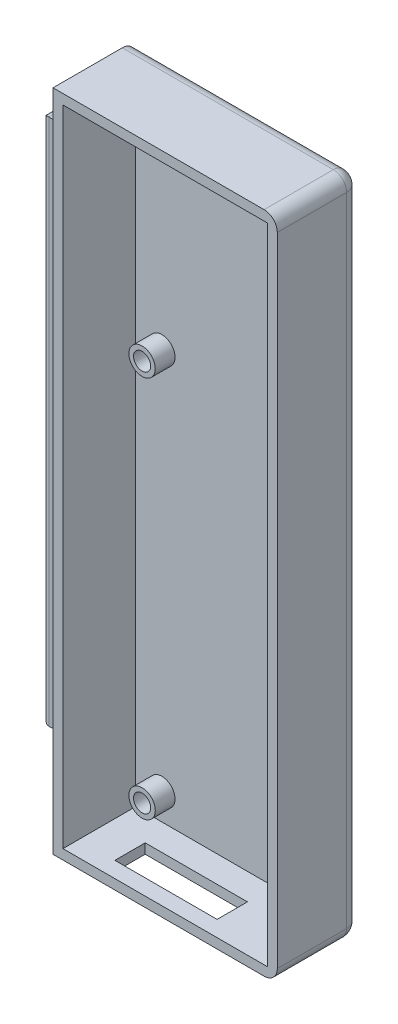
from build123d import *

# Parameters (mm, degrees)
ESQUISSE1_W             = 34
ESQUISSE1_H             = 100.65
BOSS_EXTRU_1_DEPTH      = 12.5
ESQUISSE2_W             = 31
ESQUISSE2_H             = 97.65
ENL_V_MAT_EXTRU_1_DEPTH = 11
ESQUISSE5_R             = 2
BOSS_EXTRU_4_DEPTH      = 3
CONG_2_R                = 2
CONG_3_R                = 2
CONG_4_R                = 2
ESQUISSE7_W             = 7.5
ESQUISSE7_H             = 80
BOSS_EXTRU_6_DEPTH      = 1
ESQUISSE9_W             = 9.45
ESQUISSE9_H             = 80
BOSS_EXTRU_7_DEPTH      = 1.7
ESQUISSE11_W            = 15.5
ESQUISSE11_H            = 4.6
ENL_V_MAT_EXTRU_3_DEPTH = 3
CONG_7_R                = 1
ESQUISSE12_R            = 1.3
ENL_V_MAT_EXTRU_5_DEPTH = 3


with BuildPart() as part:
    # Esquisse1 → Boss.-Extru.1 (new body)
    with BuildSketch(Plane.XY):
        with Locations((17, 50.325)):
            Rectangle(ESQUISSE1_W, ESQUISSE1_H)
    extrude(amount=BOSS_EXTRU_1_DEPTH)

    # Esquisse2 → Enlèv. mat.-Extru.1 (cut)
    with BuildSketch(Plane.XY.offset(12.5)):
        with Locations((17, 50.325)):
            Rectangle(ESQUISSE2_W, ESQUISSE2_H)
    extrude(amount=-ENL_V_MAT_EXTRU_1_DEPTH, mode=Mode.SUBTRACT)

    # Esquisse5 → Boss.-Extru.4 (add)
    with BuildSketch(Plane.XY.offset(1.5)):
        with Locations((5.5, 63.5)):
            Circle(ESQUISSE5_R)
        with Locations((28.5, 63.5)):
            Circle(ESQUISSE5_R)
        with Locations((5.5, 5.5)):
            Circle(ESQUISSE5_R)
        with Locations((28.5, 5.5)):
            Circle(ESQUISSE5_R)
    extrude(amount=BOSS_EXTRU_4_DEPTH)

    # Congé2
    cong_2_edges = [part.edges().sort_by_distance(p)[0] for p in [
        (34, 0, 6.25),
    ]]
    fillet(cong_2_edges, radius=CONG_2_R)

    # Congé3
    cong_3_edges = [part.edges().sort_by_distance(p)[0] for p in [
        (34, 100.65, 6.25),
    ]]
    fillet(cong_3_edges, radius=CONG_3_R)

    # Congé4
    cong_4_edges = [part.edges().sort_by_distance(p)[0] for p in [
        (34, 50.325, 0),
        (33.414213562, 0.585786438, 0),
        (16, 100.65, 0),
        (33.414213562, 100.064213562, 0),
        (16, 0, 0),
    ]]
    fillet(cong_4_edges, radius=CONG_4_R)

    # Esquisse7 → Boss.-Extru.6 (add)
    with BuildSketch(Plane.ZY):
        with Locations((7, 55.45)):
            Rectangle(ESQUISSE7_W, ESQUISSE7_H)
    extrude(amount=BOSS_EXTRU_6_DEPTH)

    # Esquisse9 → Boss.-Extru.7 (add)
    with BuildSketch(Plane.ZY.offset(1)):
        with Locations((6.725, 55.45)):
            Rectangle(ESQUISSE9_W, ESQUISSE9_H)
    extrude(amount=BOSS_EXTRU_7_DEPTH)

    # Esquisse11 → Enlèv. mat.-Extru.3 (cut)
    with BuildSketch(Plane(origin=(0, 1.5, 0), x_dir=(1, 0, 0), z_dir=(0, 1, 0))):
        with Locations((14.724178104, -7.8)):
            Rectangle(ESQUISSE11_W, ESQUISSE11_H)
    extrude(amount=-ENL_V_MAT_EXTRU_3_DEPTH, mode=Mode.SUBTRACT)

    # Congé7
    cong_7_edges = [part.edges().sort_by_distance(p)[0] for p in [
        (-2.7, 55.45, 2),
        (-2.7, 15.45, 6.725),
        (-2.7, 55.45, 11.45),
        (-2.7, 95.45, 6.725),
    ]]
    fillet(cong_7_edges, radius=CONG_7_R)

    # Esquisse12 → Enlèv. mat.-Extru.5 (cut)
    with BuildSketch(Plane.XY.offset(4.5)):
        with Locations((5.5, 63.5)):
            Circle(ESQUISSE12_R)
        with Locations((28.5, 63.5)):
            Circle(ESQUISSE12_R)
        with Locations((5.5, 5.5)):
            Circle(ESQUISSE12_R)
        with Locations((28.5, 5.5)):
            Circle(ESQUISSE12_R)
    extrude(amount=-ENL_V_MAT_EXTRU_5_DEPTH, mode=Mode.SUBTRACT)


solid = part.part
